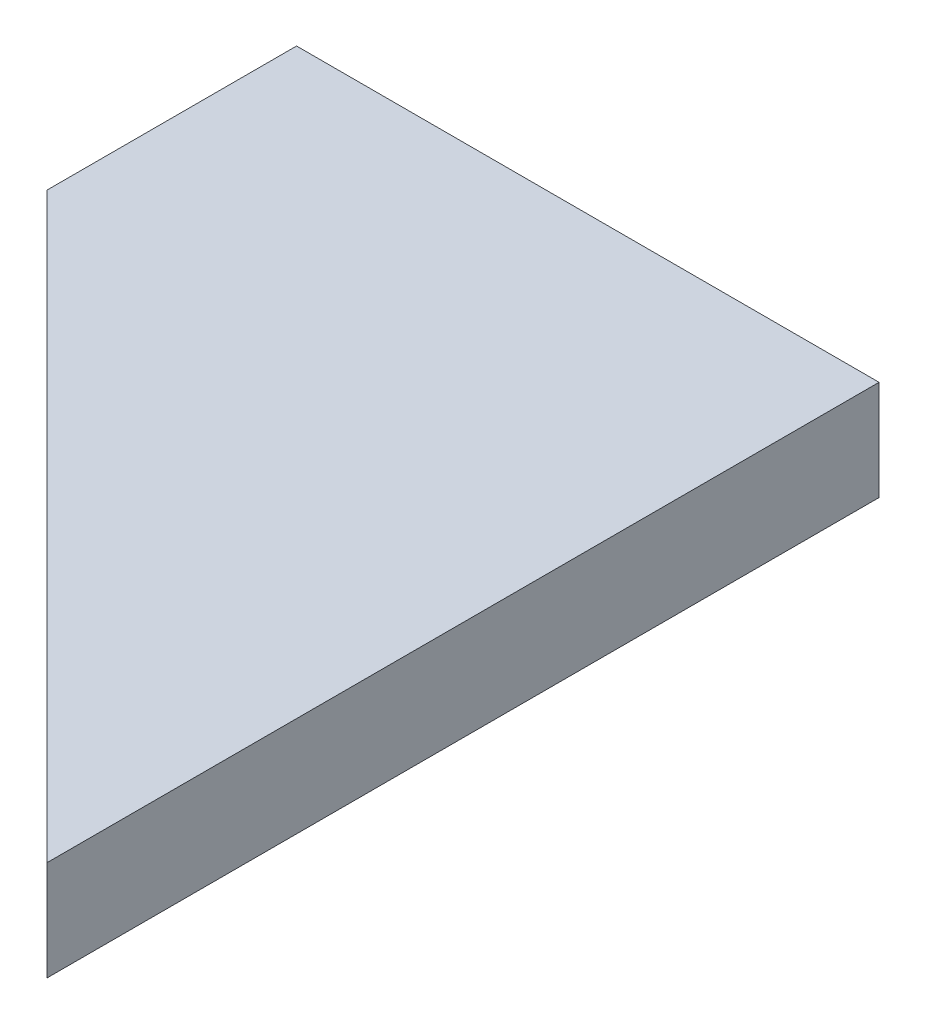
from build123d import *

# Parameters (mm, degrees)
SALIENTE_EXTRUIR1_DEPTH = 4


with BuildPart() as part:
    # Croquis1 → Saliente-Extruir1 (new body)
    with BuildSketch(Plane(origin=(0, 0, 0), x_dir=(1, 0, 0), z_dir=(0, 1, 0))):
        Polygon((-11.66726189, 6.66726189), (11.66726189, -16.66726189), (11.66726189, 16.66726189), (-11.66726189, 16.66726189), align=None)
    extrude(amount=SALIENTE_EXTRUIR1_DEPTH)


solid = part.part
